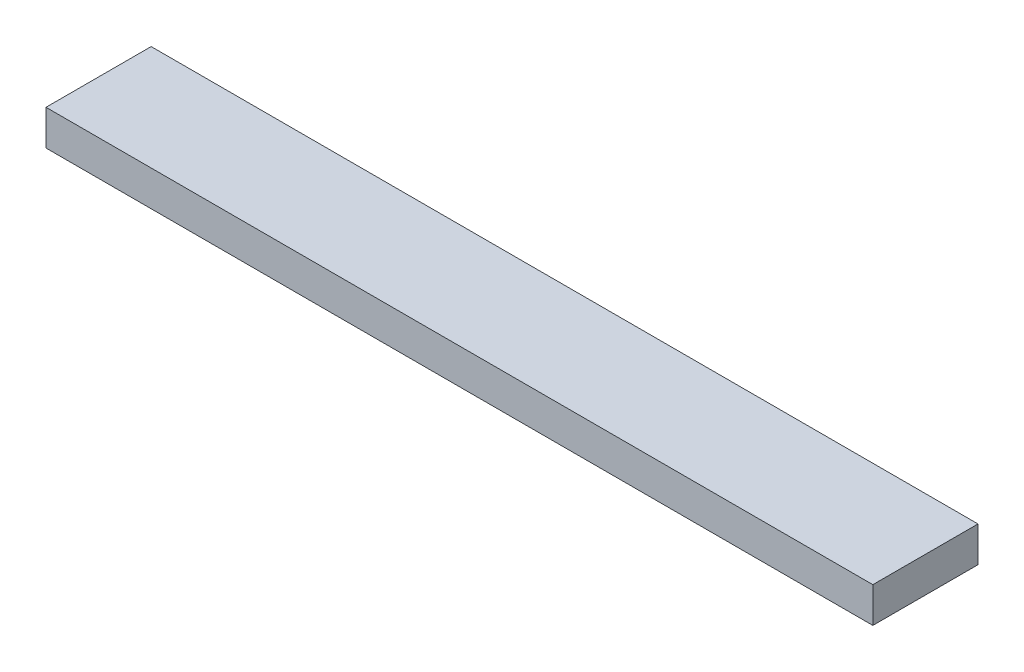
from build123d import *

# Parameters (mm, degrees)
SKETCH_1_W          = 515
SKETCH_1_H          = 135
EXTRUDE_1_DEPTH     = 22
SKETCH_2_W          = 515
SKETCH_2_H          = 69.5
CUT_EXTRUDE_1_DEPTH = 23


with BuildPart() as part:
    # Эскиз1 → Бобышка-Вытянуть1 (new body)
    with BuildSketch(Plane(origin=(0, 0, 0), x_dir=(1, 0, 0), z_dir=(0, 1, 0))):
        Rectangle(SKETCH_1_W, SKETCH_1_H)
    extrude(amount=EXTRUDE_1_DEPTH)

    # Эскиз2 → Вырез-Вытянуть1 (cut, through all)
    with BuildSketch(Plane(origin=(0, 22, 0), x_dir=(1, 0, 0), z_dir=(0, 1, 0))):
        with Locations((0, -32.75)):
            Rectangle(SKETCH_2_W, SKETCH_2_H)
    extrude(amount=-CUT_EXTRUDE_1_DEPTH, mode=Mode.SUBTRACT)


solid = part.part
